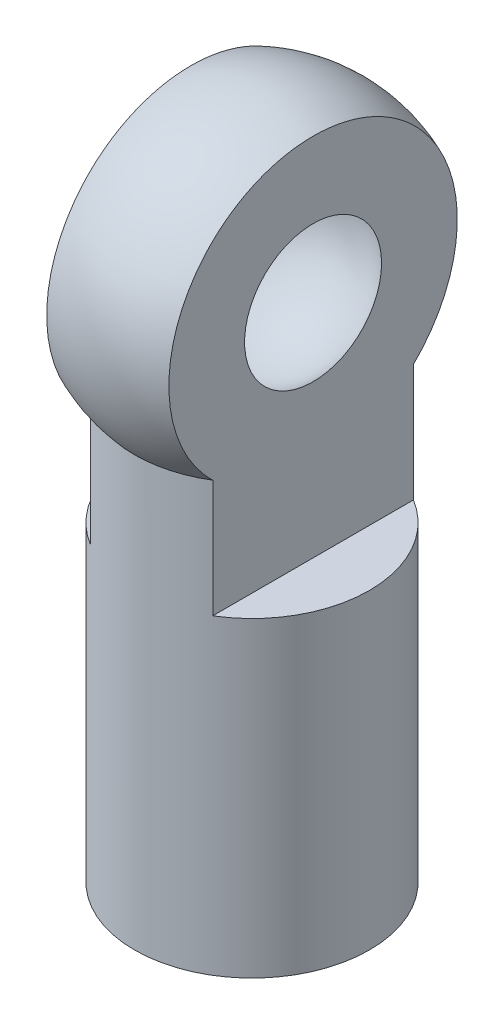
from build123d import *

# Parameters (mm, degrees)
CUT_EXTRUDE1_START      = -1.8
CUT_EXTRUDE1_DEPTH      = 4.05
SKETCH6_R               = 1.5
CUT_EXTRUDE2_DEPTH      = 1
CUT_EXTRUDE2_DEPTH_BACK = 10


with BuildPart() as part:
    # Sketch4 → Revolve2 (revolve)
    with BuildSketch(Plane.XY):
        with BuildLine():
            Line((0, 13.692810861), (0, 0))
            Line((0, 0), (3.75, 0))
            Line((3.75, 0), (3.75, 13.692810861))
            ThreePointArc((3.75, 13.692810861), (4.557189139, 19.057189139), (0, 22))
            Line((0, 22), (0, 19.93))
            ThreePointArc((0, 19.93), (2.93, 17), (0, 14.07))
            Line((0, 14.07), (0, 13.692810861))
        make_face()
    revolve(axis=Axis((0, 26.788570074, 0), (0, -1, 0)))

    # Sketch5 → Cut-Extrude1 (cut)
    with BuildSketch(Plane(origin=(3.75, 0, 0), x_dir=(0, 0, -1), z_dir=(1, 0, 0)).offset(CUT_EXTRUDE1_START)):
        with BuildLine():
            Line((-3.75, 9.942810861), (3.75, 9.942810861))
            Line((3.75, 9.942810861), (3.75, 13.692810861))
            ThreePointArc((3.75, 13.692810861), (0, 22), (-3.75, 13.692810861))
            Line((-3.75, 13.692810861), (-3.75, 9.942810861))
        make_face()
    cut_extrude1 = extrude(amount=CUT_EXTRUDE1_DEPTH, mode=Mode.SUBTRACT)

    # Mirror2: Cut-Extrude1 across plane
    add(cut_extrude1.mirror(Plane(origin=(0, 0, 0), x_dir=(0, 0, 1), z_dir=(1, 0, 0))), mode=Mode.SUBTRACT)

    # Sketch6 → Cut-Extrude2 (cut, two sides)
    with BuildSketch(Plane.XZ) as cut_extrude2_sk:
        Circle(SKETCH6_R)
    extrude(amount=CUT_EXTRUDE2_DEPTH, mode=Mode.SUBTRACT)
    extrude(cut_extrude2_sk.sketch, amount=-CUT_EXTRUDE2_DEPTH_BACK, mode=Mode.SUBTRACT)


solid = part.part
